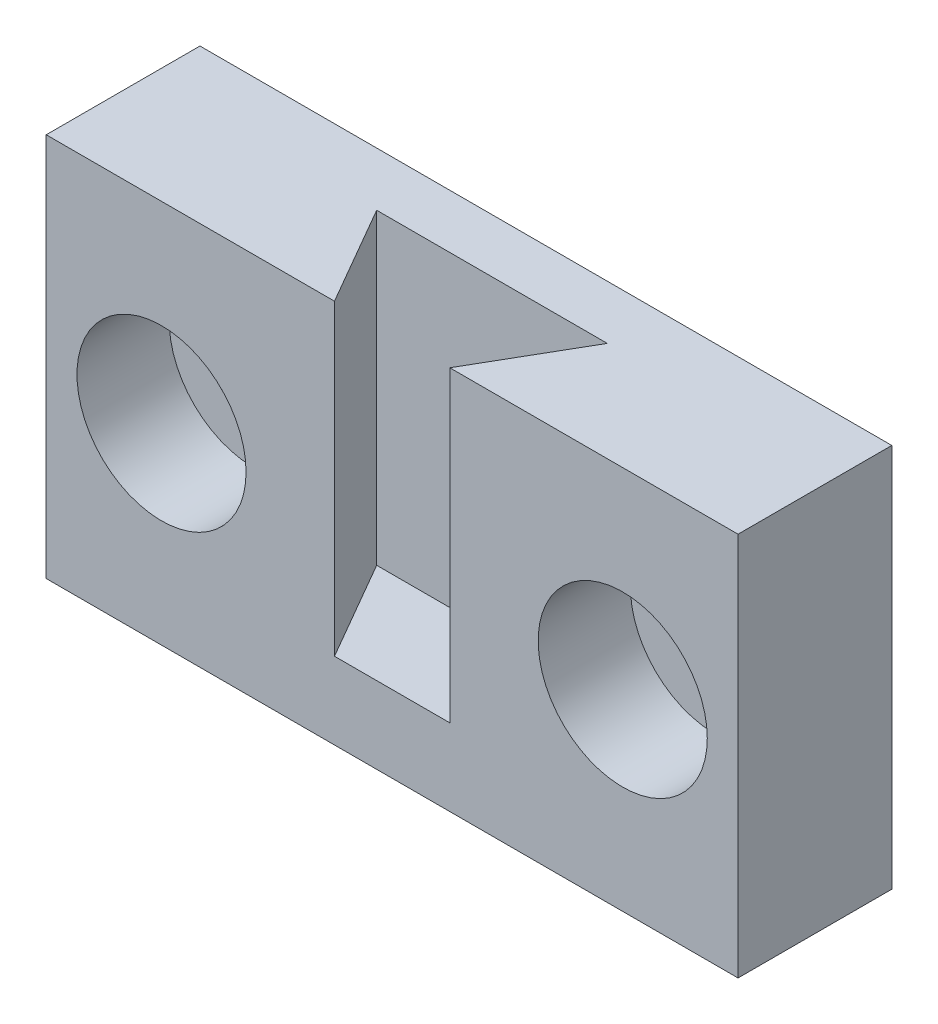
from build123d import *

# Parameters (mm, degrees)
BOSS_EXTRUDE1_DEPTH                                 = 10
BOSS_EXTRUDE2_DEPTH                                 = 2
CBORE_FOR_M2_HEX_SOCKET_HEAD_CAP_SCREW1_D           = 2.4
CBORE_FOR_M2_HEX_SOCKET_HEAD_CAP_SCREW1_CBORE_D     = 4.4
CBORE_FOR_M2_HEX_SOCKET_HEAD_CAP_SCREW1_CBORE_DEPTH = 2.4


with BuildPart() as part:
    # Sketch1 → Boss-Extrude1 (new body)
    with BuildSketch(Plane(origin=(0, 0, 0), x_dir=(1, 0, 0), z_dir=(0, 1, 0))):
        Polygon((-9, 0), (9, 0), (9, -4), (1.5, -4), (3, -1.401923789), (-3, -1.401923789), (-1.5, -4), (-9, -4), align=None)
    extrude(amount=BOSS_EXTRUDE1_DEPTH)

    # Sketch2 → Boss-Extrude2 (add)
    with BuildSketch(Plane.XZ):
        Polygon((-1.5, 4), (1.5, 4), (3, 1.401923789), (0.56541664, 1.071774791), (-3, 1.401923789), align=None)
    extrude(amount=-BOSS_EXTRUDE2_DEPTH)

    # CBORE for M2 Hex Socket Head Cap Screw1 (through all)
    with Locations(Plane.XY.offset(4)):
        with Locations((-6, 5), (6, 5)):
            CounterBoreHole(CBORE_FOR_M2_HEX_SOCKET_HEAD_CAP_SCREW1_D / 2, CBORE_FOR_M2_HEX_SOCKET_HEAD_CAP_SCREW1_CBORE_D / 2, CBORE_FOR_M2_HEX_SOCKET_HEAD_CAP_SCREW1_CBORE_DEPTH)


solid = part.part
